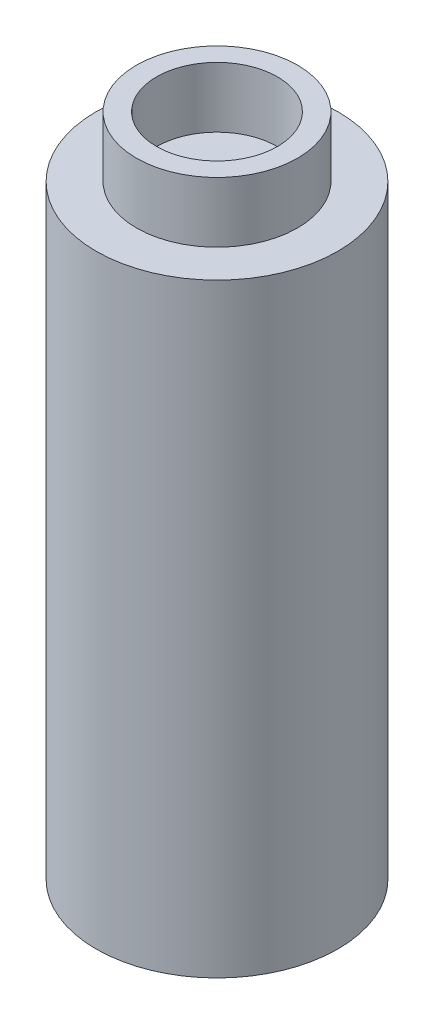
from build123d import *

# Parameters (mm, degrees)
SKETCH2_R           = 6
BOSS_EXTRUDE1_DEPTH = 30
SKETCH3_R           = 4
BOSS_EXTRUDE2_DEPTH = 3
SKETCH4_R           = 3
CUT_EXTRUDE1_DEPTH  = 3


with BuildPart() as part:
    # Sketch2 → Boss-Extrude1 (new body)
    with BuildSketch(Plane(origin=(0, 0, 0), x_dir=(1, 0, 0), z_dir=(0, 1, 0))):
        Circle(SKETCH2_R)
    extrude(amount=BOSS_EXTRUDE1_DEPTH)

    # Sketch3 → Boss-Extrude2 (add)
    with BuildSketch(Plane(origin=(0, 30, 0), x_dir=(1, 0, 0), z_dir=(0, 1, 0))):
        Circle(SKETCH3_R)
    extrude(amount=BOSS_EXTRUDE2_DEPTH)

    # Sketch4 → Cut-Extrude1 (cut)
    with BuildSketch(Plane(origin=(0, 33, 0), x_dir=(1, 0, 0), z_dir=(0, 1, 0))):
        Circle(SKETCH4_R)
    extrude(amount=-CUT_EXTRUDE1_DEPTH, mode=Mode.SUBTRACT)


solid = part.part
